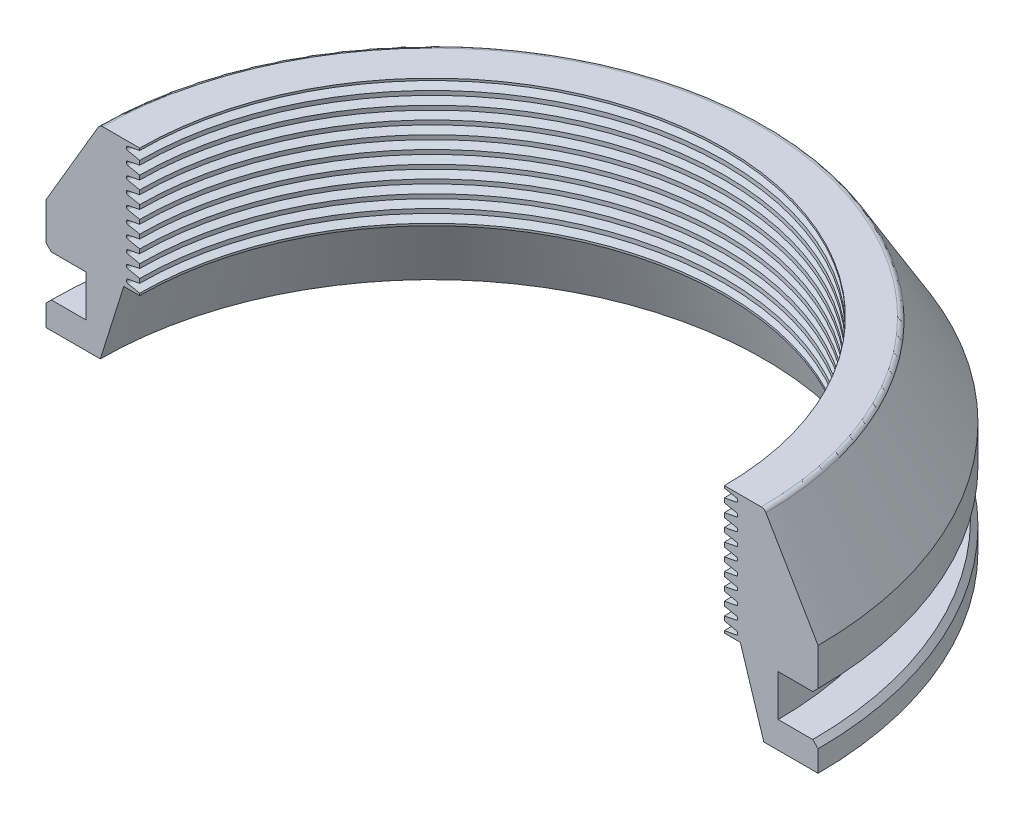
from build123d import *

# Parameters (mm, degrees)
REVOLVE1_ANGLE = 180
CHAMFER1_SIZE  = 1.27
FILLET1_R      = 1.27


with BuildPart() as part:
    # Sketch2 → Revolve1 (revolve)
    with BuildSketch(Plane.XY):
        Polygon((0, 0), (0, 6.35), (9.525, 6.35), (9.525, 16.256), (0, 16.256), (0, 26.416), (12.827, 48.26), (22.352, 48.26), (22.352, 17.78), (18.542, 17.78), (12.954, 0), align=None)
    revolve(axis=Axis((92.075, 0, 0), (0, -1, 0)), revolution_arc=REVOLVE1_ANGLE)

    # Chamfer1
    chamfer1_edges = [part.edges().sort_by_distance(p)[0] for p in [
        (92.075, 16.256, -92.075),
        (92.075, 6.35, -92.075),
    ]]
    chamfer(chamfer1_edges, length=CHAMFER1_SIZE)

    # Fillet1
    fillet1_edges = [part.edges().sort_by_distance(p)[0] for p in [
        (92.075, 48.26, -79.248),
    ]]
    fillet(fillet1_edges, radius=FILLET1_R)

    # Sketch3 → Cut-Revolve2 (revolve, cut)
    with BuildSketch(Plane.XY):
        with BuildLine():
            Line((22.352, 18.288), (22.352, 20.32))
            Line((22.352, 20.32), (19.483279753, 19.746255951))
            ThreePointArc((19.483279753, 19.746255951), (19.263356644, 19.614204486), (19.177, 19.372654713))
            Line((19.177, 19.372654713), (19.177, 19.235345287))
            ThreePointArc((19.177, 19.235345287), (19.263356644, 18.993795514), (19.483279753, 18.861744049))
            Line((19.483279753, 18.861744049), (22.352, 18.288))
        make_face()
        with BuildLine():
            Line((22.352, 21.336), (22.352, 23.368))
            Line((22.352, 23.368), (19.483279753, 22.794255951))
            ThreePointArc((19.483279753, 22.794255951), (19.263356644, 22.662204486), (19.177, 22.420654713))
            Line((19.177, 22.420654713), (19.177, 22.283345287))
            ThreePointArc((19.177, 22.283345287), (19.263356644, 22.041795514), (19.483279753, 21.909744049))
            Line((19.483279753, 21.909744049), (22.352, 21.336))
        make_face()
        with BuildLine():
            Line((22.352, 24.384), (22.352, 26.416))
            Line((22.352, 26.416), (19.483279753, 25.842255951))
            ThreePointArc((19.483279753, 25.842255951), (19.263356644, 25.710204486), (19.177, 25.468654713))
            Line((19.177, 25.468654713), (19.177, 25.331345287))
            ThreePointArc((19.177, 25.331345287), (19.263356644, 25.089795514), (19.483279753, 24.957744049))
            Line((19.483279753, 24.957744049), (22.352, 24.384))
        make_face()
        with BuildLine():
            Line((22.352, 27.432), (22.352, 29.464))
            Line((22.352, 29.464), (19.483279753, 28.890255951))
            ThreePointArc((19.483279753, 28.890255951), (19.263356644, 28.758204486), (19.177, 28.516654713))
            Line((19.177, 28.516654713), (19.177, 28.379345287))
            ThreePointArc((19.177, 28.379345287), (19.263356644, 28.137795514), (19.483279753, 28.005744049))
            Line((19.483279753, 28.005744049), (22.352, 27.432))
        make_face()
        with BuildLine():
            Line((22.352, 30.48), (22.352, 32.512))
            Line((22.352, 32.512), (19.483279753, 31.938255951))
            ThreePointArc((19.483279753, 31.938255951), (19.263356644, 31.806204486), (19.177, 31.564654713))
            Line((19.177, 31.564654713), (19.177, 31.427345287))
            ThreePointArc((19.177, 31.427345287), (19.263356644, 31.185795514), (19.483279753, 31.053744049))
            Line((19.483279753, 31.053744049), (22.352, 30.48))
        make_face()
        with BuildLine():
            Line((22.352, 33.528), (22.352, 35.56))
            Line((22.352, 35.56), (19.483279753, 34.986255951))
            ThreePointArc((19.483279753, 34.986255951), (19.263356644, 34.854204486), (19.177, 34.612654713))
            Line((19.177, 34.612654713), (19.177, 34.475345287))
            ThreePointArc((19.177, 34.475345287), (19.263356644, 34.233795514), (19.483279753, 34.101744049))
            Line((19.483279753, 34.101744049), (22.352, 33.528))
        make_face()
        with BuildLine():
            Line((22.352, 36.576), (22.352, 38.608))
            Line((22.352, 38.608), (19.483279753, 38.034255951))
            ThreePointArc((19.483279753, 38.034255951), (19.263356644, 37.902204486), (19.177, 37.660654713))
            Line((19.177, 37.660654713), (19.177, 37.523345287))
            ThreePointArc((19.177, 37.523345287), (19.263356644, 37.281795514), (19.483279753, 37.149744049))
            Line((19.483279753, 37.149744049), (22.352, 36.576))
        make_face()
        with BuildLine():
            Line((22.352, 39.624), (22.352, 41.656))
            Line((22.352, 41.656), (19.483279753, 41.082255951))
            ThreePointArc((19.483279753, 41.082255951), (19.263356644, 40.950204486), (19.177, 40.708654713))
            Line((19.177, 40.708654713), (19.177, 40.571345287))
            ThreePointArc((19.177, 40.571345287), (19.263356644, 40.329795514), (19.483279753, 40.197744049))
            Line((19.483279753, 40.197744049), (22.352, 39.624))
        make_face()
        with BuildLine():
            Line((22.352, 42.672), (22.352, 44.704))
            Line((22.352, 44.704), (19.483279753, 44.130255951))
            ThreePointArc((19.483279753, 44.130255951), (19.263356644, 43.998204486), (19.177, 43.756654713))
            Line((19.177, 43.756654713), (19.177, 43.619345287))
            ThreePointArc((19.177, 43.619345287), (19.263356644, 43.377795514), (19.483279753, 43.245744049))
            Line((19.483279753, 43.245744049), (22.352, 42.672))
        make_face()
        with BuildLine():
            Line((22.352, 45.72), (22.352, 47.752))
            Line((22.352, 47.752), (19.483279753, 47.178255951))
            ThreePointArc((19.483279753, 47.178255951), (19.263356644, 47.046204486), (19.177, 46.804654713))
            Line((19.177, 46.804654713), (19.177, 46.667345287))
            ThreePointArc((19.177, 46.667345287), (19.263356644, 46.425795514), (19.483279753, 46.293744049))
            Line((19.483279753, 46.293744049), (22.352, 45.72))
        make_face()
    revolve(axis=Axis((92.075, 0, 0), (0, 1, 0)), mode=Mode.SUBTRACT)


solid = part.part
